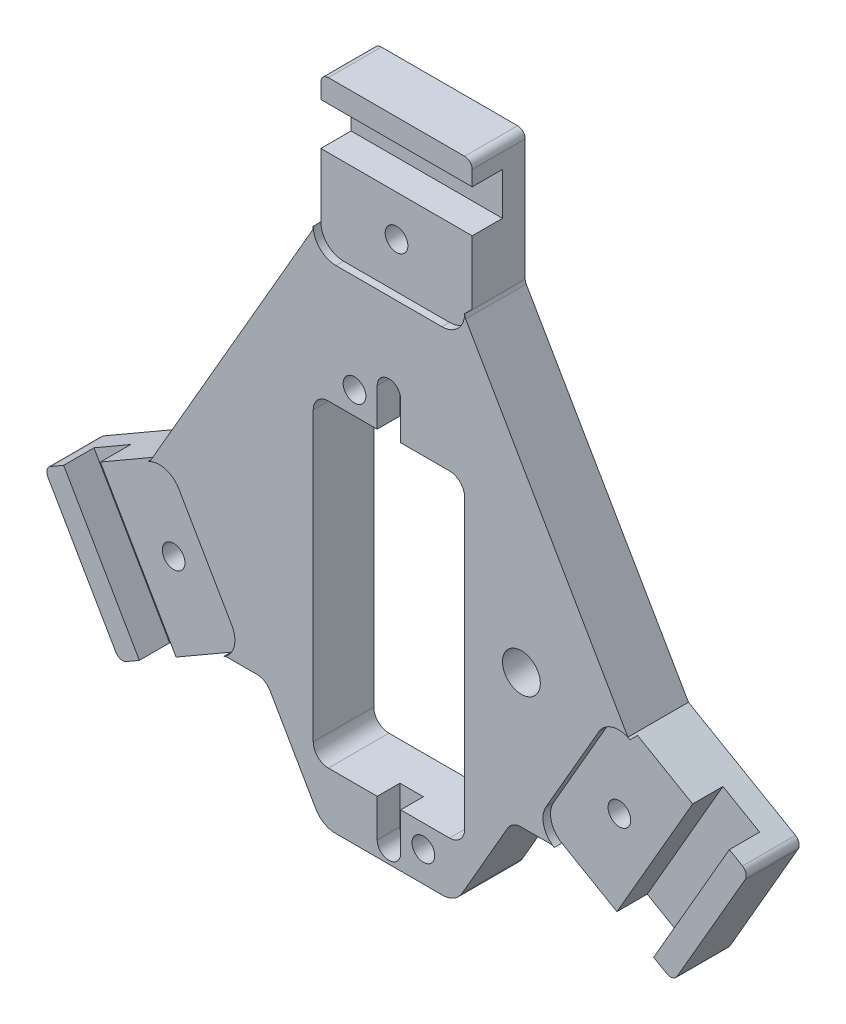
from build123d import *

# Parameters (mm, degrees)
BOSS_EXTRUDE1_DEPTH = 8
CUT_EXTRUDE1_DEPTH  = 1
SKETCH3_R           = 1.5
CUT_EXTRUDE2_DEPTH  = 68.243529011
SKETCH4_W           = 20
SKETCH4_H           = 5.6
CUT_EXTRUDE3_DEPTH  = 4
SKETCH5_R           = 1.5
SKETCH5_R_2         = 2.5
CUT_EXTRUDE5_DEPTH  = 68.35497156
CUT_EXTRUDE6_DEPTH  = 3
FILLET1_R           = 1
FILLET2_R           = 3
FILLET3_R           = 2
FILLET4_R           = 1
FILLET6_R           = 1


with BuildPart() as part:
    # Sketch1 → Boss-Extrude1 (new body)
    with BuildSketch(Plane.XY):
        Polygon((-10, 30.679491924), (-10, 48), (10, 48), (10, 30.679491924), (31.569219382, -6.679491924), (46.569219382, -15.339745962), (36.569219382, -32.660254038), (21.569219382, -24), (16.278513086, -24), (8.795198312, -37), (-8.795198312, -37), (-16.278513086, -24), (-21.569219382, -24), (-36.569219382, -32.660254038), (-46.569219382, -15.339745962), (-31.569219382, -6.679491924), align=None)
    extrude(amount=BOSS_EXTRUDE1_DEPTH)

    # Sketch2 → Cut-Extrude1 (cut)
    with BuildSketch(Plane.XY.offset(8)):
        with BuildLine():
            Line((-36.569219382, -32.660254038), (-46.569219382, -15.339745962))
            Line((-46.569219382, -15.339745962), (-31.846787517, -6.839745962))
            ThreePointArc((-31.846787517, -6.839745962), (-29.570330382, -6.540044695), (-27.748711306, -7.937822174))
            Line((-27.748711306, -7.937822174), (-20.748711306, -20.062177826))
            ThreePointArc((-20.748711306, -20.062177826), (-20.449010038, -22.338634962), (-21.846787517, -24.160254038))
            Line((-21.846787517, -24.160254038), (-36.569219382, -32.660254038))
        make_face()
        with BuildLine():
            Line((-7, 28), (7, 28))
            ThreePointArc((7, 28), (9.121320344, 28.878679656), (10, 31))
            Line((10, 31), (10, 48))
            Line((10, 48), (-10, 48))
            Line((-10, 48), (-10, 31))
            ThreePointArc((-10, 31), (-9.121320344, 28.878679656), (-7, 28))
        make_face()
        with BuildLine():
            Line((36.569219382, -32.660254038), (46.569219382, -15.339745962))
            Line((46.569219382, -15.339745962), (31.846787517, -6.839745962))
            ThreePointArc((31.846787517, -6.839745962), (29.570330382, -6.540044695), (27.748711306, -7.937822174))
            Line((27.748711306, -7.937822174), (20.748711306, -20.062177826))
            ThreePointArc((20.748711306, -20.062177826), (20.449010038, -22.338634962), (21.846787517, -24.160254038))
            Line((21.846787517, -24.160254038), (36.569219382, -32.660254038))
        make_face()
    extrude(amount=-CUT_EXTRUDE1_DEPTH, mode=Mode.SUBTRACT)

    # Sketch3 → Cut-Extrude2 (cut, through all)
    with BuildSketch(Plane.XY.offset(7)):
        with Locations((0, 34)):
            Circle(SKETCH3_R)
        with Locations((29.444863729, -17)):
            Circle(SKETCH3_R)
        with Locations((-29.444863729, -17)):
            Circle(SKETCH3_R)
    extrude(amount=-CUT_EXTRUDE2_DEPTH, mode=Mode.SUBTRACT)

    # Sketch4 → Cut-Extrude3 (cut)
    with BuildSketch(Plane.XY.offset(7)):
        with Locations((0, 42.2)):
            Rectangle(SKETCH4_W, SKETCH4_H)
        Polygon((39.121400909, -11.039745962), (43.97114317, -13.839745962), (33.97114317, -31.160254038), (29.121400909, -28.360254038), align=None)
        Polygon((-43.97114317, -13.839745962), (-39.121400909, -11.039745962), (-29.121400909, -28.360254038), (-33.97114317, -31.160254038), align=None)
    extrude(amount=-CUT_EXTRUDE3_DEPTH, mode=Mode.SUBTRACT)

    # Sketch5 → Cut-Extrude5 (cut, through all)
    with BuildSketch(Plane.XY.offset(8)):
        with BuildLine():
            ThreePointArc((-10, -28), (-9.414213562, -29.414213562), (-8, -30))
            Line((-8, -30), (8, -30))
            ThreePointArc((8, -30), (9.414213562, -29.414213562), (10, -28))
            Line((10, -28), (10, 10))
            ThreePointArc((10, 10), (9.414213562, 11.414213562), (8, 12))
            Line((8, 12), (-8, 12))
            ThreePointArc((-8, 12), (-9.414213562, 11.414213562), (-10, 10))
            Line((-10, 10), (-10, -28))
        make_face()
        with Locations((4.55, -33)):
            Circle(SKETCH5_R)
        with Locations((-4.55, 15)):
            Circle(SKETCH5_R)
        with Locations((17.5, -6.310889132)):
            Circle(SKETCH5_R_2)
    extrude(amount=-CUT_EXTRUDE5_DEPTH, mode=Mode.SUBTRACT)

    # Sketch5_3 → Cut-Extrude6 (cut)
    with BuildSketch(Plane.XY.offset(8)):
        with BuildLine():
            Line((1.55, -30), (-1.55, -30))
            Line((-1.55, -30), (-1.55, -35))
            ThreePointArc((-1.55, -35), (0, -36.55), (1.55, -35))
            Line((1.55, -35), (1.55, -30))
        make_face()
        with BuildLine():
            Line((-1.55, 17), (-1.55, 12))
            Line((-1.55, 12), (1.55, 12))
            Line((1.55, 12), (1.55, 17))
            ThreePointArc((1.55, 17), (0, 18.55), (-1.55, 17))
        make_face()
    extrude(amount=-CUT_EXTRUDE6_DEPTH, mode=Mode.SUBTRACT)

    # Fillet1
    fillet1_edges = [part.edges().sort_by_distance(p)[0] for p in [
        (10, 48, 3.5),
        (-10, 48, 3.5),
        (-36.569219382, -32.660254038, 3.5),
        (-46.569219382, -15.339745962, 3.5),
        (36.569219382, -32.660254038, 3.5),
        (46.569219382, -15.339745962, 3.5),
    ]]
    fillet(fillet1_edges, radius=FILLET1_R)

    # Fillet2
    fillet2_edges = [part.edges().sort_by_distance(p)[0] for p in [
        (-8.795198312, -37, 4),
        (8.795198312, -37, 4),
    ]]
    fillet(fillet2_edges, radius=FILLET2_R)

    # Fillet3
    fillet3_edges = [part.edges().sort_by_distance(p)[0] for p in [
        (16.278513086, -24, 4),
        (-16.278513086, -24, 4),
    ]]
    fillet(fillet3_edges, radius=FILLET3_R)

    # Fillet4
    fillet4_edges = [part.edges().sort_by_distance(p)[0] for p in [
        (10, 30.679491924, 4),
    ]]
    fillet(fillet4_edges, radius=FILLET4_R)

    # Fillet6
    fillet6_edges = [part.edges().sort_by_distance(p)[0] for p in [
        (-10, 30.679491924, 4),
    ]]
    fillet(fillet6_edges, radius=FILLET6_R)


solid = part.part
